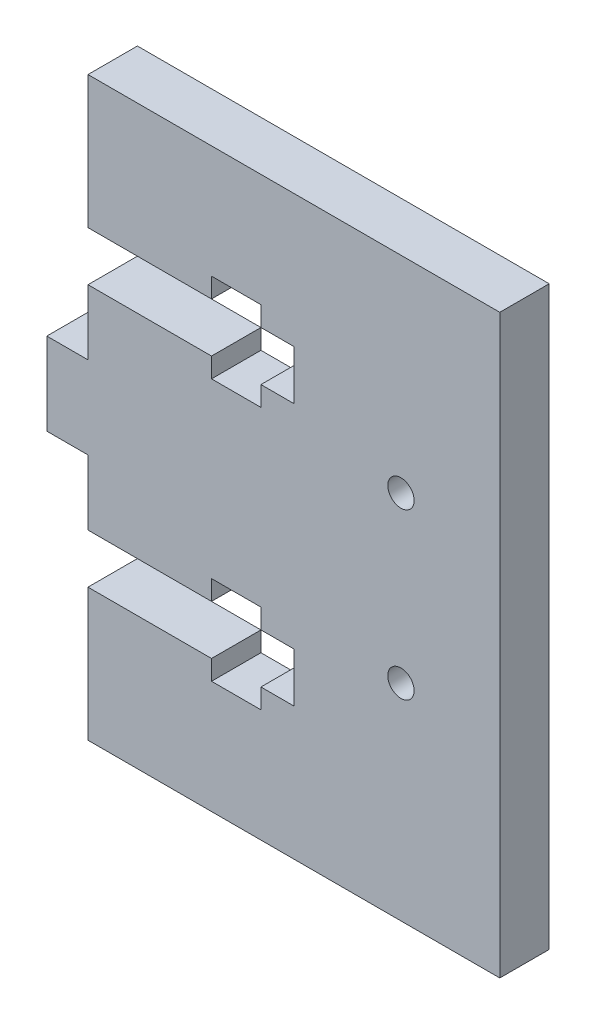
from build123d import *

# Parameters (mm, degrees)
SKETCH1_R           = 1.6
BOSS_EXTRUDE1_DEPTH = 6


with BuildPart() as part:
    # Sketch1 → Boss-Extrude1 (new body)
    with BuildSketch(Plane.XY):
        Polygon((-121, -35), (-71, -35), (-71, 35), (-121, 35), (-121, 18.9), (-106, 18.9), (-106, 21.3), (-100, 21.3), (-100, 18.9), (-96, 18.9), (-96, 12.9), (-100, 12.9), (-100, 10.5), (-106, 10.5), (-106, 12.9), (-121, 12.9), (-121, 5), (-126, 5), (-126, -5), (-121, -5), (-121, -12.9), (-106, -12.9), (-106, -10.5), (-100, -10.5), (-100, -12.9), (-96, -12.9), (-96, -18.9), (-100, -18.9), (-100, -21.3), (-106, -21.3), (-106, -18.9), (-121, -18.9), align=None)
        with Locations((-83, -10)):
            Circle(SKETCH1_R, mode=Mode.SUBTRACT)
        with Locations((-83, 10)):
            Circle(SKETCH1_R, mode=Mode.SUBTRACT)
    extrude(amount=BOSS_EXTRUDE1_DEPTH)


solid = part.part
